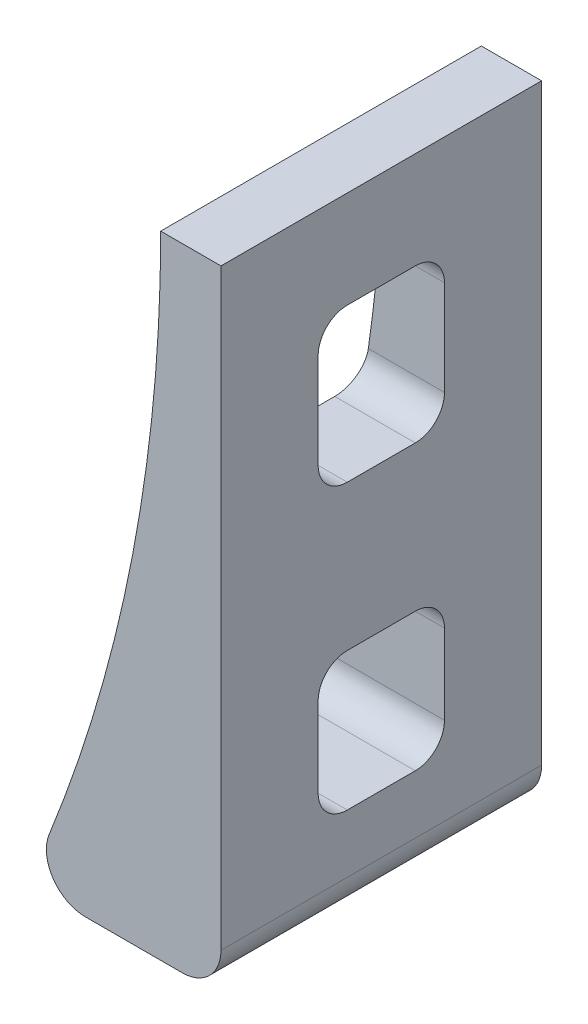
from build123d import *

# Parameters (mm, degrees)
RESSALTO_EXTRUS_O1_DEPTH = 33
CORTE_EXTRUS_O1_DEPTH    = 33
FILETE1_R                = 4


with BuildPart() as part:
    # Esboço1 → Ressalto-extrusão1 (new body)
    with BuildSketch(Plane.XY):
        with BuildLine():
            Line((-20.29157915, 93.135393664), (-14.089663978, 93.135393664))
            Line((-14.089663978, 93.135393664), (-14.089663978, 28.135393664))
            Line((-14.089663978, 28.135393664), (-34.089663978, 28.135393664))
            ThreePointArc((-34.089663978, 28.135393664), (-23.779109315, 59.911203888), (-20.29157915, 93.135393664))
        make_face()
    extrude(amount=RESSALTO_EXTRUS_O1_DEPTH)

    # Esboço2 → Corte-extrusão1 (cut)
    with BuildSketch(Plane(origin=(-14.089663978, 0, 0), x_dir=(0, 0, -1), z_dir=(1, 0, 0))):
        with BuildLine():
            Line((-20, 83.135393664), (-13, 83.135393664))
            ThreePointArc((-13, 83.135393664), (-10.878679656, 82.256714007), (-10, 80.135393664))
            Line((-10, 80.135393664), (-10, 70.356838266))
            ThreePointArc((-10, 70.356838266), (-10.878679656, 68.235517922), (-13, 67.356838266))
            Line((-13, 67.356838266), (-20, 67.356838266))
            ThreePointArc((-20, 67.356838266), (-22.121320344, 68.235517922), (-23, 70.356838266))
            Line((-23, 70.356838266), (-23, 80.135393664))
            ThreePointArc((-23, 80.135393664), (-22.121320344, 82.256714007), (-20, 83.135393664))
        make_face()
        with BuildLine():
            Line((-20, 52.356838266), (-13, 52.356838266))
            ThreePointArc((-13, 52.356838266), (-10.878679656, 51.478158609), (-10, 49.356838266))
            Line((-10, 49.356838266), (-10, 41.135393664))
            ThreePointArc((-10, 41.135393664), (-10.878679656, 39.01407332), (-13, 38.135393664))
            Line((-13, 38.135393664), (-20, 38.135393664))
            ThreePointArc((-20, 38.135393664), (-22.121320344, 39.01407332), (-23, 41.135393664))
            Line((-23, 41.135393664), (-23, 49.356838266))
            ThreePointArc((-23, 49.356838266), (-22.121320344, 51.478158609), (-20, 52.356838266))
        make_face()
    extrude(amount=-CORTE_EXTRUS_O1_DEPTH, mode=Mode.SUBTRACT)

    # Filete1
    filete1_edges = [part.edges().sort_by_distance(p)[0] for p in [
        (-14.089663978, 28.135393664, 16.5),
        (-34.089663978, 28.135393664, 16.5),
    ]]
    fillet(filete1_edges, radius=FILETE1_R)


solid = part.part
